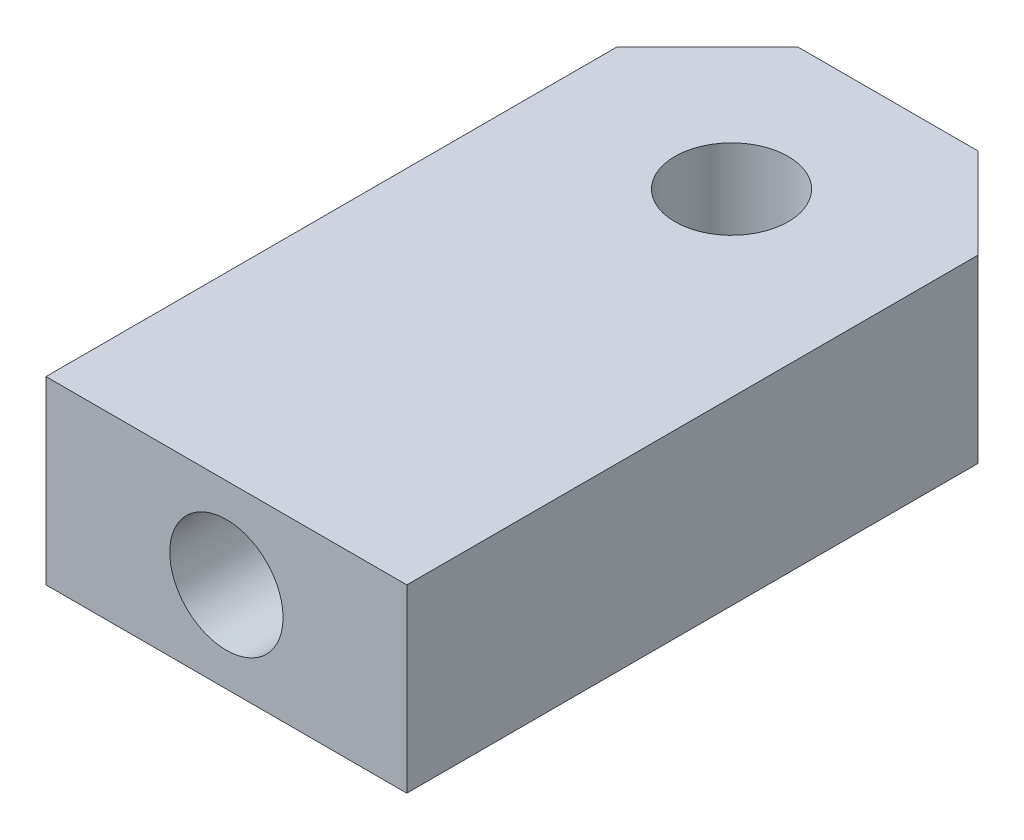
from build123d import *

# Parameters (mm, degrees)
SKETCH2_R           = 1.57
BOSS_EXTRUDE1_DEPTH = 5
SKETCH3_R           = 1.57
CUT_EXTRUDE1_DEPTH  = 8


with BuildPart() as part:
    # Sketch2 → Boss-Extrude1 (new body)
    with BuildSketch(Plane(origin=(0, 0, 0), x_dir=(1, 0, 0), z_dir=(0, 1, 0))):
        Polygon((-5, 1.830127019), (-5, 0), (-5, -14), (5, -14), (5, 0), (5, 1.830127019), (2.5, 4.330127019), (-2.5, 4.330127019), align=None)
        Circle(SKETCH2_R, mode=Mode.SUBTRACT)
    extrude(amount=BOSS_EXTRUDE1_DEPTH)

    # Sketch3 → Cut-Extrude1 (cut)
    with BuildSketch(Plane.XY.offset(14)):
        with Locations((0, 2.5)):
            Circle(SKETCH3_R)
    extrude(amount=-CUT_EXTRUDE1_DEPTH, mode=Mode.SUBTRACT)


solid = part.part
